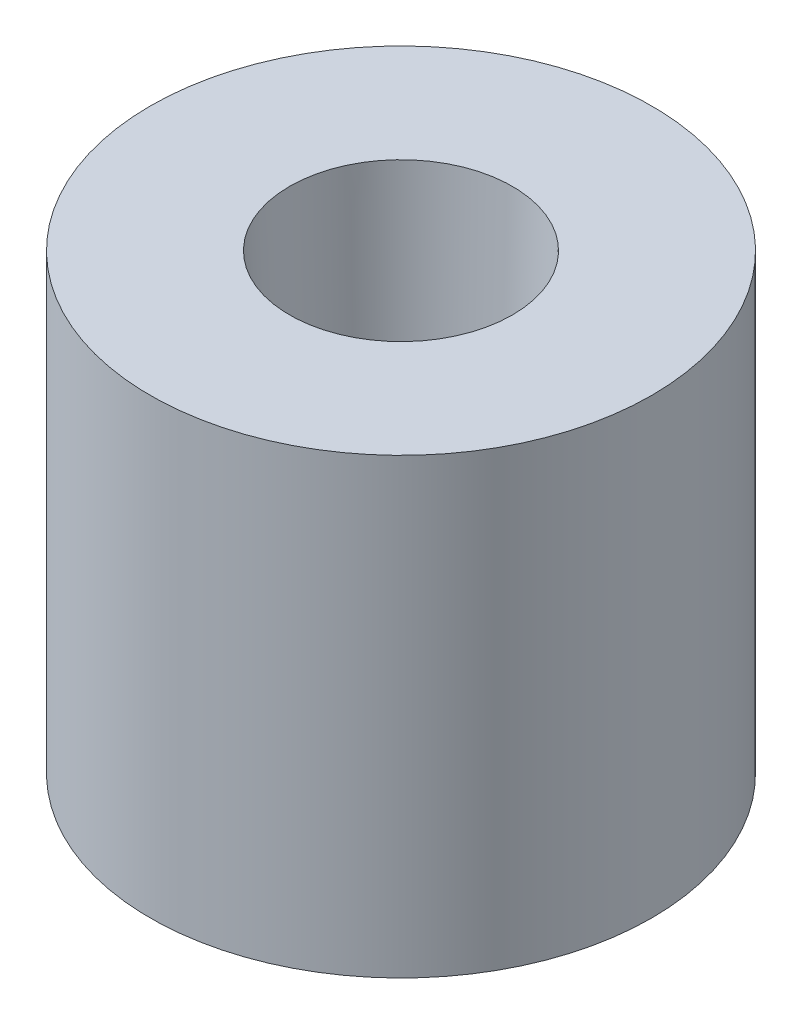
from build123d import *


with BuildPart() as part:
    # Sketch1 → Revolve1 (revolve)
    with BuildSketch(Plane.XY):
        Polygon((0, 0), (-3.6, 0), (-3.6, 6.5), (-1.6, 6.5), (-1.43, 1.5), (0, 1.5), align=None)
    revolve(axis=Axis((0, 1.5, 0), (0, -1, 0)))


solid = part.part
